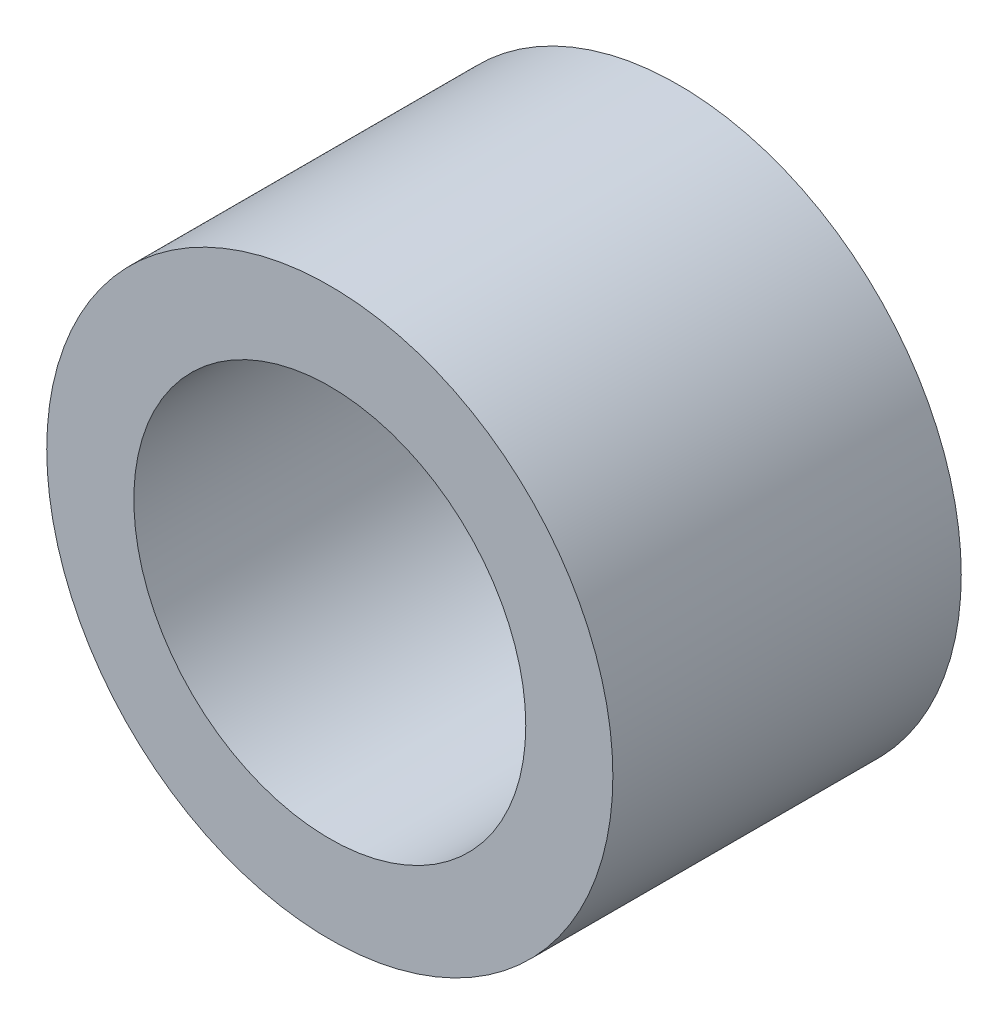
from build123d import *

# Parameters (mm, degrees)
SKETCH1_R           = 3.25
SKETCH1_R_2         = 2.25
BOSS_EXTRUDE1_DEPTH = 4


with BuildPart() as part:
    # Sketch1 → Boss-Extrude1 (new body)
    with BuildSketch(Plane.XY):
        Circle(SKETCH1_R)
        Circle(SKETCH1_R_2, mode=Mode.SUBTRACT)
    extrude(amount=BOSS_EXTRUDE1_DEPTH)


solid = part.part
